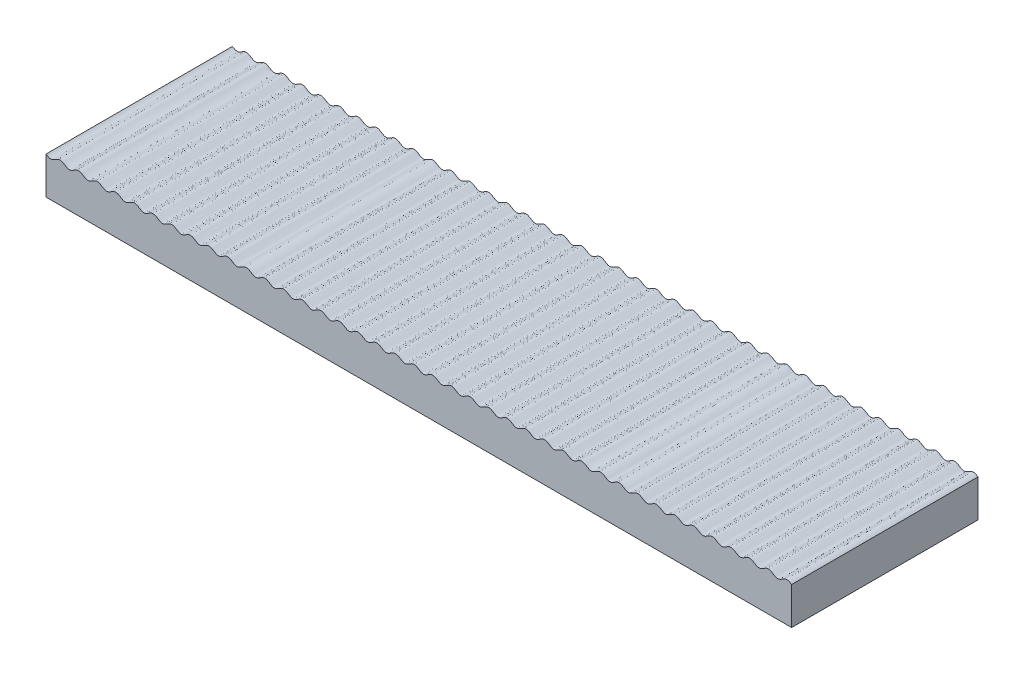
from build123d import *

# Parameters (mm, degrees)
AUFSATZ_LINEAR_AUSTRAGEN1_DEPTH = 50


with BuildPart() as part:
    # Skizze1 → Aufsatz-Linear austragen1 (new body)
    with BuildSketch(Plane.XY):
        with BuildLine():
            add(Edge.make_bspline(
                [(0, 10), (0.058156395, 9.963459259), (0.174460896, 9.890382969), (0.435101092, 9.731843137), (0.714087592, 9.597566249), (1.046515843, 9.497036845), (1.403971077, 9.487186717), (1.749790734, 9.579846915), (2.069063006, 9.734806523), (2.362766313, 9.911941759), (2.641470938, 10.09074218), (2.93530101, 10.267642414), (3.254955395, 10.421972045), (3.600976413, 10.513524398), (3.958973412, 10.501814768), (4.367324276, 10.378064372), (4.800523182, 10.135115226), (5.207839743, 9.859414186), (5.64181751, 9.617602261), (6.051047747, 9.496493028), (6.409156305, 9.48773138), (6.835297845, 9.603887267), (7.291634153, 9.858998024), (7.720930307, 10.149230223), (8.178537369, 10.402455149), (8.606040235, 10.514225581), (8.963982417, 10.500893098), (9.37188542, 10.375913276), (9.804704587, 10.132358406), (10.212022863, 9.856686806), (10.646395971, 9.615455469), (11.056064638, 9.495663385), (11.414214387, 9.488424678), (11.839896882, 9.60602139), (12.295819968, 9.861744303), (12.725121125, 10.151969209), (13.183162132, 10.404549595), (13.611113272, 10.514835545), (13.968985643, 10.499982768), (14.376443405, 10.373731897), (14.808884051, 10.129614331), (15.216208168, 9.853953116), (15.650979728, 9.613321399), (16.06108518, 9.494852372), (16.41926866, 9.489139474), (16.844489808, 9.608164644), (17.300004725, 9.864492876), (17.729313454, 10.154706034), (18.187793585, 10.406634115), (18.616190045, 10.515424234), (18.97398549, 10.499052867), (19.380996731, 10.371541181), (19.813062818, 10.126868075), (20.220395118, 9.851221375), (20.655569135, 9.611196955), (21.066109263, 9.494061485), (21.424319168, 9.48987498), (21.849076702, 9.610317388), (22.304188541, 9.867243404), (22.733507371, 10.157440899), (23.192431843, 10.408708525), (23.621270531, 10.515991602), (23.978981965, 10.498103468), (24.385545506, 10.369341203), (24.817240982, 10.12411963), (25.22458381, 9.84849159), (25.660164301, 9.609082214), (26.071136884, 9.493290816), (26.4293659, 9.490631101), (26.853657675, 9.612479541), (27.308371507, 9.869995881), (27.737702972, 10.160173804), (28.197077016, 10.410772728), (28.62635471, 10.516537564), (28.983975074, 10.497134664), (29.390089838, 10.367132026), (29.821418636, 10.121369002), (30.228774339, 9.845763762), (30.664765336, 9.606977258), (31.076168039, 9.492540454), (31.434408851, 9.491407745), (31.858232839, 9.614651028), (32.312553712, 9.872750306), (32.741900352, 10.162904752), (33.20172921, 10.412826623), (33.63144256, 10.517062037), (33.988964826, 10.496146549), (34.394629835, 10.36491371), (34.825595872, 10.118616195), (35.232966803, 9.843037892), (35.669372349, 9.604882171), (36.081202722, 9.491810485), (36.439448012, 9.492204817), (36.862802306, 9.616831771), (37.316735245, 9.875506674), (37.746099607, 10.165633742), (38.206388535, 10.414870108), (38.636534059, 10.517564935), (38.99395123, 10.495139219), (39.399165602, 10.362686307), (39.82977279, 10.115861231), (40.237161283, 9.84031395), (40.673985472, 9.602797084), (41.086240894, 9.491100935), (41.444483451, 9.493022357), (41.867366033, 9.619021401), (42.320916553, 9.878265662), (42.750300232, 10.168359631), (43.211055876, 10.416904561), (43.641627945, 10.518043829), (43.998936789, 10.494117505), (44.40369163, 10.360439187), (44.833964015, 10.113131835), (45.241331914, 9.837542114), (45.678640093, 9.600790877), (46.10290311, 9.48718836), (46.486282911, 9.495948391), (46.921696455, 9.644415114), (47.379540192, 9.917697089), (47.805654805, 10.202776898), (48.250463008, 10.430525205), (48.68134184, 10.521220329), (49.05932099, 10.48499648), (49.467920633, 10.328243363), (49.892347812, 10.07297639), (50.289642048, 9.809294826), (50.700270135, 9.593993393), (51.085308476, 9.492913003), (51.417208693, 9.493260789), (51.802046623, 9.594998345), (52.212492628, 9.810622783), (52.609709166, 10.074368802), (53.034350072, 10.329407303), (53.448726674, 10.487813733), (53.839667296, 10.522157903), (54.286608846, 10.417843831), (54.747597847, 10.169780212), (55.176993477, 9.879610964), (55.630353948, 9.620134992), (56.053000351, 9.493431717), (56.411238657, 9.49075713), (56.823705681, 9.601756075), (57.260740662, 9.838954311), (57.668138857, 10.114482052), (58.098568061, 10.361569557), (58.503556823, 10.494628226), (58.86091883, 10.517808344), (59.291279097, 10.415887867), (59.751800031, 10.16699754), (60.181174213, 9.876885565), (60.634915061, 9.617925601), (61.05803383, 9.492610979), (61.416278615, 9.491453178), (61.828321868, 9.603838355), (62.264936209, 9.841675693), (62.672315639, 10.117238975), (63.103101758, 10.363801143), (63.508541555, 10.495645278), (63.866012145, 10.517316188), (64.295942025, 10.413849673), (64.75600026, 10.164269492), (65.185355443, 9.874128247), (65.639481722, 9.615740247), (66.063071095, 9.491803734), (66.42131506, 9.492172915), (66.832931911, 9.605928476), (67.269129677, 9.844400582), (67.676492699, 10.11999287), (68.107639629, 10.366024007), (68.513529631, 10.496643014), (68.871101823, 10.516802492), (69.300597771, 10.41180097), (69.760198566, 10.161539523), (70.189537301, 9.87137285), (70.644054024, 9.613564123), (71.068112151, 9.491016864), (71.42634798, 9.492913091), (71.837535922, 9.608028507), (72.273321161, 9.847127431), (72.680670133, 10.122744588), (73.11218178, 10.368237761), (73.51852106, 10.497621486), (73.87618784, 10.516267264), (74.305246441, 10.409741909), (74.764395045, 10.158807596), (75.193719875, 9.868619399), (75.648632079, 9.611397293), (76.073156994, 9.490250469), (76.431377368, 9.493673618), (76.842134009, 9.610138366), (77.277510759, 9.849856238), (77.68484803, 10.125494125), (78.116728319, 10.370442346), (78.523515851, 10.498580599), (78.881270175, 10.515710588), (79.309888143, 10.40767259), (79.768589792, 10.156073711), (80.197903255, 9.865867896), (80.653215998, 9.609239835), (81.078205615, 9.489504644), (81.436403221, 9.494454407), (81.846726282, 9.612257969), (82.281698568, 9.852587001), (82.689026485, 10.128241477), (83.121279356, 10.372637701), (83.528514011, 10.499520261), (83.886348807, 10.515132549), (84.314522985, 10.405593112), (84.772782903, 10.153337866), (85.20208753, 9.863118345), (85.657805894, 9.607091826), (86.083258006, 9.488779481), (86.441425534, 9.495255368), (86.85131285, 9.614387235), (87.285884684, 9.855319719), (87.693205588, 10.130986638), (88.125834999, 10.374823763), (88.533515547, 10.500440378), (88.891423716, 10.514533232), (89.319151076, 10.403503573), (89.776974473, 10.150600062), (90.206272792, 9.860370749), (90.662401879, 9.604953347), (91.088314159, 9.488075073), (91.446444305, 9.496076412), (91.855893822, 9.616526085), (92.290069203, 9.858054391), (92.697385434, 10.133729607), (93.130395356, 10.377000468), (93.538520462, 10.50134086), (93.896494884, 10.513912724), (94.323772525, 10.401404067), (94.781164595, 10.147860298), (95.21045913, 9.857625108), (95.667004063, 9.602824482), (96.09337406, 9.487391512), (96.451459533, 9.496917448), (96.86046931, 9.618674443), (97.294252222, 9.860791016), (97.701566117, 10.136470379), (98.134960536, 10.37916775), (98.543528762, 10.502221615), (98.901562295, 10.513271114), (99.328387442, 10.399294686), (99.785353363, 10.145118574), (100.214646637, 9.854881426), (100.671612558, 9.600705315), (101.098437705, 9.486728886), (101.456471238, 9.497778385), (101.865039464, 9.62083225), (102.298433883, 9.863529621), (102.705747778, 10.139208985), (103.13953069, 10.381325557), (103.548540467, 10.503082552), (103.90662594, 10.512608488), (104.332995937, 10.397175518), (104.78954087, 10.142374892), (105.218835405, 9.852139702), (105.676227475, 9.598595933), (106.103505116, 9.486087276), (106.461479538, 9.49865914), (106.869604644, 9.622999532), (107.302614566, 9.866270393), (107.709930797, 10.141945609), (108.144106178, 10.383473915), (108.553555695, 10.503923588), (108.911685841, 10.511924927), (109.337598121, 10.395046653), (109.793727208, 10.139629251), (110.223025527, 9.849399938), (110.680848924, 9.596496427), (111.108576284, 9.485466768), (111.466484453, 9.499559622), (111.874165001, 9.625176237), (112.306794412, 9.869013362), (112.714115316, 10.144680281), (113.14868715, 10.385612765), (113.558574466, 10.504744632), (113.916741994, 10.511220519), (114.342194106, 10.392908174), (114.797912469, 10.136881655), (115.227217097, 9.846662134), (115.685477015, 9.594406888), (116.113651193, 9.484867451), (116.471485989, 9.50047974), (116.878720644, 9.6273623), (117.310973515, 9.871758523), (117.718301432, 10.147412999), (118.153273718, 10.387742031), (118.563596779, 10.505545593), (118.921794385, 10.510495356), (119.346784002, 10.390760165), (119.802096745, 10.134132104), (120.231410208, 9.843926289), (120.690111857, 9.59232741), (121.118729825, 9.484289412), (121.476484149, 9.501419401), (121.883271681, 9.629557654), (122.31515197, 9.874505875), (122.72248924, 10.150143762), (123.157865991, 10.389861634), (123.568622632, 10.506326382), (123.926843006, 10.509749531), (124.351367921, 10.388602707), (124.806280125, 10.131380601), (125.235604955, 9.841192404), (125.694753559, 9.590258091), (126.12381216, 9.483732736), (126.48147894, 9.502378514), (126.88781822, 9.631762239), (127.319329867, 9.877255412), (127.726678839, 10.152872569), (128.162464078, 10.391971493), (128.57365202, 10.507086909), (128.931887849, 10.508983136), (129.355945976, 10.386435877), (129.810462699, 10.12862715), (130.239801433, 9.838460477), (130.699402229, 9.58819903), (131.128898177, 9.483197508), (131.486470369, 9.503356986), (131.892360371, 9.633975993), (132.3235073, 9.88000713), (132.730870323, 10.155599418), (133.167068088, 10.394071524), (133.57868494, 10.507827085), (133.936928905, 10.508196266), (134.360518278, 10.384259753), (134.814644557, 10.125871753), (135.243999739, 9.835730508), (135.704057975, 9.586150327), (136.133987855, 9.482683812), (136.491458445, 9.504354722), (136.896898242, 9.636198857), (137.327684361, 9.882761025), (137.735063791, 10.158324307), (138.171678132, 10.396161645), (138.583721385, 10.508546822), (138.94196617, 10.507389021), (139.36508494, 10.382074399), (139.818825785, 10.123114436), (140.248199972, 9.833002459), (140.7087209, 9.584112133), (141.139081176, 9.482191655), (141.496443165, 9.505371776), (141.901431966, 9.638430439), (142.331861071, 9.885517959), (142.739259466, 10.161045669), (143.17629414, 10.398243952), (143.588761606, 10.50924283), (143.946999086, 10.50656837), (144.369647286, 10.379864817), (144.823003717, 10.120389469), (145.252406839, 9.830219062), (145.713385241, 9.5821571), (146.160342087, 9.477840551), (146.551254329, 9.512190038), (146.895759123, 9.643853548), (147.198892269, 9.810729636), (147.471180995, 9.981540091), (147.721943873, 10.140545767), (147.985779157, 10.293458262), (148.270446893, 10.424232581), (148.582763309, 10.506696704), (148.914703515, 10.507105066), (149.299723009, 10.405996289), (149.710363055, 10.190712853), (150.107649185, 9.927019091), (150.532080755, 9.671758726), (150.940678363, 9.515002546), (151.318658469, 9.478780137), (151.749536802, 9.56947451), (152.194345345, 9.797223328), (152.620459716, 10.082302772), (153.07830359, 10.355584954), (153.513717067, 10.504051577), (153.8970969, 10.512811655), (154.321359901, 10.399209113), (154.758668091, 10.162457893), (155.166035982, 9.886868161), (155.596308371, 9.639560815), (156.00106321, 9.505882494), (156.358372055, 9.481956171), (156.788944124, 9.583095439), (157.249699768, 9.831640369), (157.679083447, 10.121734337), (158.132633967, 10.380978599), (158.555516549, 10.506977643), (158.913759106, 10.508899066), (159.326014528, 10.397202916), (159.762838717, 10.15968605), (160.17022721, 9.884138769), (160.600834398, 9.637313694), (161.00604877, 9.504860781), (161.363465941, 9.482435065), (161.793611465, 9.585129892), (162.253900392, 9.834366258), (162.683264755, 10.124493326), (163.137197694, 10.383168229), (163.560551988, 10.507795183), (163.918797278, 10.508189515), (164.330627651, 10.395117829), (164.767033197, 10.156962108), (165.174404128, 9.881383805), (165.605370165, 9.63508629), (166.011035174, 9.503853451), (166.36855744, 9.482937963), (166.798270789, 9.587173377), (167.258099648, 9.837095248), (167.687446288, 10.127249694), (168.141767161, 10.385348972), (168.565591149, 10.508592255), (168.923831961, 10.507459546), (169.335234664, 10.393022742), (169.771225661, 10.154236238), (170.178581364, 9.878630998), (170.609910162, 9.632867974), (171.016024926, 9.502865336), (171.37364529, 9.483462436), (171.802922984, 9.589227272), (172.262297028, 9.839826196), (172.691628493, 10.130004119), (173.146342325, 10.387520459), (173.5706341, 10.509368899), (173.928863116, 10.506709184), (174.339835699, 10.390917786), (174.77541619, 10.15150841), (175.182759018, 9.87588037), (175.614454494, 9.630658797), (176.021018035, 9.501896532), (176.378729469, 9.484008398), (176.807568157, 9.591291475), (177.266492629, 9.842559101), (177.695811459, 10.132756596), (178.150923298, 10.389682613), (178.575680832, 10.51012502), (178.933890737, 10.505938515), (179.344430865, 10.388803045), (179.779604881, 10.148778625), (180.186937182, 9.873131926), (180.619003269, 9.628458819), (181.02601451, 9.500947133), (181.383809955, 9.484575766), (181.812206415, 9.593365885), (182.270686546, 9.845293966), (182.699995275, 10.135507124), (183.155510192, 10.391835356), (183.58073134, 10.510860526), (183.93891482, 10.505147629), (184.349020272, 10.386678601), (184.783791832, 10.146046884), (185.191115949, 9.870385669), (185.623556595, 9.626268103), (186.031014357, 9.500017232), (186.388886728, 9.485164455), (186.816837868, 9.595450405), (187.274878875, 9.848030791), (187.704180032, 10.138255697), (188.160103118, 10.39397861), (188.585785613, 10.511575323), (188.943935362, 10.504336615), (189.353604029, 10.384544531), (189.787977137, 10.143313194), (190.195295413, 9.867641594), (190.62811458, 9.624086724), (191.036017583, 9.499106902), (191.393959765, 9.485774419), (191.821462631, 9.597544851), (192.279069693, 9.850769777), (192.708365847, 10.141001976), (193.164702155, 10.396112733), (193.590843695, 10.51226862), (193.948952253, 10.503506972), (194.35818249, 10.382397739), (194.792160257, 10.140585814), (195.199476817, 9.864884774), (195.632675724, 9.621935628), (196.041026588, 9.498185232), (196.399023587, 9.486475602), (196.745044605, 9.578027955), (197.06469899, 9.732357586), (197.358529062, 9.90925782), (197.637233687, 10.088058241), (197.930936994, 10.265193477), (198.250209266, 10.420153085), (198.596028923, 10.512813283), (198.953484157, 10.502963155), (199.285912408, 10.402433751), (199.564898907, 10.268156863), (199.825539104, 10.109617031), (199.941843605, 10.036540741), (200, 10)],
                knots=[0.082583232, 0.082583232, 0.082583232, 0.082583232, 0.082583232, 0.083841025, 0.085098819, 0.086356612, 0.087614405, 0.089055173, 0.09049594, 0.091762085, 0.093028231, 0.094294376, 0.095560522, 0.097001276, 0.09844203, 0.09969982, 0.10095761, 0.10347319, 0.105988782, 0.107246578, 0.108504374, 0.109945155, 0.111385936, 0.113918228, 0.11645052, 0.117891262, 0.119332004, 0.12058979, 0.121847577, 0.12436315, 0.126878745, 0.128136542, 0.129394339, 0.130835136, 0.132275932, 0.134808225, 0.137340518, 0.13878125, 0.140221981, 0.141479763, 0.142737546, 0.145253111, 0.147768706, 0.149026503, 0.150284301, 0.151725114, 0.153165927, 0.155698222, 0.158230517, 0.159671239, 0.16111196, 0.162369738, 0.163627517, 0.166143073, 0.168658666, 0.169916462, 0.171174258, 0.172615089, 0.17405592, 0.176588218, 0.179120516, 0.180561229, 0.182001942, 0.183259715, 0.184517489, 0.187033035, 0.189548624, 0.190806418, 0.192064213, 0.193505062, 0.194945911, 0.197478213, 0.200010514, 0.20145122, 0.202891926, 0.204149694, 0.205407462, 0.207922998, 0.21043858, 0.211696372, 0.212954163, 0.214395031, 0.2158359, 0.218368206, 0.220900512, 0.222341212, 0.223781911, 0.225039674, 0.226297436, 0.228812962, 0.231328535, 0.232586322, 0.233844108, 0.235284998, 0.236725887, 0.239258198, 0.241790509, 0.243231204, 0.244671898, 0.245929655, 0.247187411, 0.249702925, 0.252218487, 0.253476268, 0.25473405, 0.256174961, 0.257615872, 0.260148189, 0.262680505, 0.264121196, 0.265561887, 0.266819637, 0.268077387, 0.270592888, 0.273108437, 0.274366212, 0.275623986, 0.277247955, 0.278871924, 0.281312592, 0.28375326, 0.285102364, 0.286451469, 0.287959388, 0.289467307, 0.291737389, 0.294007472, 0.295260684, 0.296513897, 0.297767112, 0.299020328, 0.301290416, 0.303560504, 0.305068427, 0.30657635, 0.30801704, 0.309457729, 0.311990048, 0.314522368, 0.315963291, 0.317404213, 0.318661991, 0.319919769, 0.322435325, 0.324950833, 0.326208586, 0.32746634, 0.328907032, 0.330347724, 0.332880038, 0.335412352, 0.336853252, 0.338294152, 0.339551936, 0.340809721, 0.343325289, 0.345840808, 0.347098568, 0.348356327, 0.349797024, 0.351237721, 0.353770029, 0.356302338, 0.357743217, 0.359184096, 0.360441885, 0.361699674, 0.364215252, 0.366730783, 0.367988548, 0.369246314, 0.370687016, 0.372127719, 0.374660022, 0.377192326, 0.378633185, 0.380074044, 0.381331837, 0.382589629, 0.385105215, 0.387620757, 0.388878528, 0.390136298, 0.391577008, 0.393017717, 0.395550017, 0.398082316, 0.399523156, 0.400963996, 0.402221791, 0.403479587, 0.405995178, 0.408510729, 0.409768505, 0.411026281, 0.412466998, 0.413907715, 0.416440012, 0.418972309, 0.42041313, 0.421853952, 0.423111749, 0.424369546, 0.42688514, 0.429400701, 0.430658481, 0.431916262, 0.433356988, 0.434797714, 0.437330008, 0.439862302, 0.441303107, 0.442743912, 0.444001709, 0.445259507, 0.447775101, 0.450290671, 0.451548455, 0.45280624, 0.454246976, 0.455687713, 0.458220005, 0.460752297, 0.462193086, 0.463633875, 0.464891672, 0.466149468, 0.468665062, 0.471180639, 0.472438427, 0.473696215, 0.475136963, 0.476577711, 0.479110002, 0.481642294, 0.483083068, 0.484523842, 0.485781637, 0.487039431, 0.489555021, 0.492070605, 0.493328396, 0.494586188, 0.496026949, 0.497467709, 0.5, 0.502532291, 0.503973051, 0.505413812, 0.506671604, 0.507929395, 0.510444979, 0.512960569, 0.514218363, 0.515476158, 0.516916932, 0.518357706, 0.520889998, 0.523422289, 0.524863037, 0.526303785, 0.527561573, 0.528819361, 0.531334938, 0.533850532, 0.535108328, 0.536366125, 0.537806914, 0.539247703, 0.541779995, 0.544312287, 0.545753024, 0.54719376, 0.548451545, 0.549709329, 0.552224899, 0.554740493, 0.555998291, 0.557256088, 0.558696893, 0.560137698, 0.562669992, 0.565202286, 0.566643012, 0.568083738, 0.569341519, 0.570599299, 0.57311486, 0.575630454, 0.576888251, 0.578146048, 0.57958687, 0.581027691, 0.583559988, 0.586092285, 0.587533002, 0.588973719, 0.590231495, 0.591489271, 0.594004822, 0.596520413, 0.597778209, 0.599036004, 0.600476844, 0.601917684, 0.604449983, 0.606982283, 0.608422992, 0.609863702, 0.611121472, 0.612379243, 0.614894785, 0.617410371, 0.618668163, 0.619925956, 0.621366815, 0.622807674, 0.625339978, 0.627872281, 0.629312984, 0.630753686, 0.632011452, 0.633269217, 0.635784748, 0.638300326, 0.639558115, 0.640815904, 0.642256783, 0.643697662, 0.646229971, 0.648762279, 0.650202976, 0.651643673, 0.652901432, 0.654159192, 0.656674711, 0.659190279, 0.660448064, 0.661705848, 0.663146748, 0.664587648, 0.667119962, 0.669652276, 0.671092968, 0.67253366, 0.673791414, 0.675049167, 0.677564675, 0.680080231, 0.681338009, 0.682595787, 0.684036709, 0.685477632, 0.688009952, 0.690542271, 0.69198296, 0.69342365, 0.694931573, 0.696439496, 0.69757454, 0.698709584, 0.699844628, 0.700979672, 0.702232888, 0.703486103, 0.704739316, 0.705992528, 0.708262611, 0.710532693, 0.712040612, 0.713548531, 0.714897636, 0.71624674, 0.718687408, 0.721128076, 0.722752045, 0.724376014, 0.725633788, 0.726891563, 0.729407112, 0.731922613, 0.733180363, 0.734438113, 0.735878804, 0.737319495, 0.739851811, 0.742384128, 0.743825039, 0.74526595, 0.746523732, 0.747781513, 0.750297075, 0.752812589, 0.754070345, 0.755328102, 0.756768796, 0.758209491, 0.760741802, 0.763274113, 0.764715002, 0.766155892, 0.767413678, 0.768671465, 0.771187038, 0.773702564, 0.774960326, 0.776218089, 0.777658788, 0.779099488, 0.781631794, 0.7841641, 0.785604969, 0.787045837, 0.788303628, 0.78956142, 0.792077002, 0.794592538, 0.795850306, 0.797108074, 0.79854878, 0.799989486, 0.802521787, 0.805054089, 0.806494938, 0.807935787, 0.809193582, 0.810451376, 0.812966965, 0.815482511, 0.816740285, 0.817998058, 0.819438771, 0.820879484, 0.823411782, 0.82594408, 0.827384911, 0.828825742, 0.830083538, 0.831341334, 0.833856927, 0.836372483, 0.837630262, 0.83888804, 0.840328761, 0.841769483, 0.844301778, 0.846834073, 0.848274886, 0.849715699, 0.850973497, 0.852231294, 0.854746889, 0.857262454, 0.858520237, 0.859778019, 0.86121875, 0.862659482, 0.865191775, 0.867724068, 0.869164864, 0.870605661, 0.871863458, 0.873121255, 0.87563685, 0.878152423, 0.87941021, 0.880667996, 0.882108738, 0.88354948, 0.886081772, 0.888614064, 0.890054845, 0.891495626, 0.892753422, 0.894011218, 0.89652681, 0.89904239, 0.90030018, 0.90155797, 0.902998724, 0.904439478, 0.905705624, 0.906971769, 0.908237915, 0.90950406, 0.910944827, 0.912385595, 0.913643388, 0.914901181, 0.916158975, 0.917416768, 0.917416768, 0.917416768, 0.917416768, 0.917416768], degree=4))
            Line((200, 10), (200, 0))
            Line((200, 0), (0, 0))
            Line((0, 0), (0, 10))
        make_face()
    extrude(amount=AUFSATZ_LINEAR_AUSTRAGEN1_DEPTH)


solid = part.part
